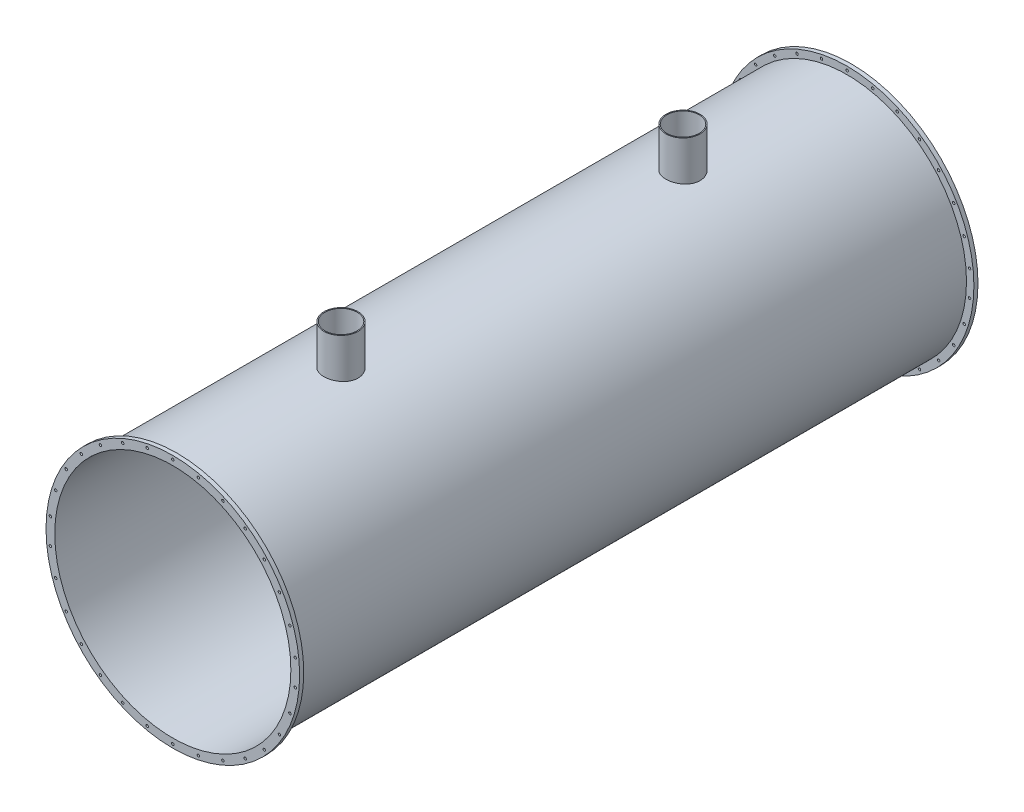
from build123d import *

# Parameters (mm, degrees)
SKETCH1_R           = 2130.025
SKETCH1_R_2         = 2105.58
BOSS_EXTRUDE1_DEPTH = 12100
BOSS_EXTRUDE2_REACH = 4962.049
SKETCH2_R           = 304.8
SKETCH3_R           = 287.4
CUT_EXTRUDE1_DEPTH  = 1000
SKETCH4_R           = 2262.0235
SKETCH4_R_2         = 2130.025
BOSS_EXTRUDE3_DEPTH = 73
SKETCH5_R           = 22
CUT_EXTRUDE2_DEPTH  = 73
SKETCH6_R           = 2262.0235
SKETCH6_R_2         = 2130.025
BOSS_EXTRUDE4_DEPTH = 73
SKETCH7_R           = 22
CUT_EXTRUDE3_DEPTH  = 73


with BuildPart() as part:
    # Sketch1 → Boss-Extrude1 (new body)
    with BuildSketch(Plane.XY):
        Circle(SKETCH1_R)
        Circle(SKETCH1_R_2, mode=Mode.SUBTRACT)
    extrude(amount=BOSS_EXTRUDE1_DEPTH)

    # Sketch2 → Boss-Extrude2 (add, up to next)
    with BuildSketch(Plane(origin=(0, 2830.0235, 0), x_dir=(1, 0, 0), z_dir=(0, 1, 0)), mode=Mode.PRIVATE) as boss_extrude2_sk1:
        with Locations((0, -3000)):
            Circle(SKETCH2_R)
    boss_extrude2_tool1 = extrude(boss_extrude2_sk1.sketch, amount=-BOSS_EXTRUDE2_REACH, mode=Mode.PRIVATE) - part.part
    add(boss_extrude2_tool1.solids().sort_by_distance((0, 2830.0235, 3000))[0])
    # Sketch2 → Boss-Extrude2 (add, up to next)
    with BuildSketch(Plane(origin=(0, 2830.0235, 0), x_dir=(1, 0, 0), z_dir=(0, 1, 0)), mode=Mode.PRIVATE) as boss_extrude2_sk2:
        with Locations((0, -9100)):
            Circle(SKETCH2_R)
    boss_extrude2_tool2 = extrude(boss_extrude2_sk2.sketch, amount=-BOSS_EXTRUDE2_REACH, mode=Mode.PRIVATE) - part.part
    add(boss_extrude2_tool2.solids().sort_by_distance((0, 2830.0235, 9100))[0])

    # Sketch3 → Cut-Extrude1 (cut)
    with BuildSketch(Plane(origin=(0, 2830.0235, 0), x_dir=(1, 0, 0), z_dir=(0, 1, 0))):
        with Locations((0, -9100)):
            Circle(SKETCH3_R)
        with Locations((0, -3000)):
            Circle(SKETCH3_R)
    extrude(amount=-CUT_EXTRUDE1_DEPTH, mode=Mode.SUBTRACT)

    # Sketch4 → Boss-Extrude3 (add)
    with BuildSketch(Plane.XY.offset(12100)):
        Circle(SKETCH4_R)
        Circle(SKETCH4_R_2, mode=Mode.SUBTRACT)
    extrude(amount=-BOSS_EXTRUDE3_DEPTH)

    # Sketch5 → Cut-Extrude2 (cut)
    with BuildSketch(Plane.XY.offset(12100)):
        with Locations((0, 2196.025)):
            Circle(SKETCH5_R)
        with Locations((456.579270828, 2148.036584901)):
            Circle(SKETCH5_R)
        with Locations((893.203836611, 2006.16866362)):
            Circle(SKETCH5_R)
        with Locations((1290.791108666, 1776.621545072)):
            Circle(SKETCH5_R)
        with Locations((1631.964615369, 1469.427539829)):
            Circle(SKETCH5_R)
        with Locations((1901.813437346, 1098.0125)):
            Circle(SKETCH5_R)
        with Locations((2088.543886197, 678.609045072)):
            Circle(SKETCH5_R)
        with Locations((2183.994945276, 229.547118548)):
            Circle(SKETCH5_R)
        with Locations((2183.994945276, -229.547118547)):
            Circle(SKETCH5_R)
        with Locations((2088.543886197, -678.609045072)):
            Circle(SKETCH5_R)
        with Locations((1901.813437346, -1098.0125)):
            Circle(SKETCH5_R)
        with Locations((1631.964615369, -1469.427539829)):
            Circle(SKETCH5_R)
        with Locations((1290.791108666, -1776.621545072)):
            Circle(SKETCH5_R)
        with Locations((893.203836611, -2006.16866362)):
            Circle(SKETCH5_R)
        with Locations((456.579270828, -2148.036584901)):
            Circle(SKETCH5_R)
        with Locations((0, -2196.025)):
            Circle(SKETCH5_R)
        with Locations((-456.579270828, -2148.036584901)):
            Circle(SKETCH5_R)
        with Locations((-893.20383661, -2006.16866362)):
            Circle(SKETCH5_R)
        with Locations((-1290.791108665, -1776.621545072)):
            Circle(SKETCH5_R)
        with Locations((-1631.964615369, -1469.427539829)):
            Circle(SKETCH5_R)
        with Locations((-1901.813437345, -1098.0125)):
            Circle(SKETCH5_R)
        with Locations((-2088.543886197, -678.609045072)):
            Circle(SKETCH5_R)
        with Locations((-2183.994945276, -229.547118548)):
            Circle(SKETCH5_R)
        with Locations((-2183.994945276, 229.547118547)):
            Circle(SKETCH5_R)
        with Locations((-2088.543886197, 678.609045072)):
            Circle(SKETCH5_R)
        with Locations((-1901.813437346, 1098.0125)):
            Circle(SKETCH5_R)
        with Locations((-1631.964615369, 1469.427539829)):
            Circle(SKETCH5_R)
        with Locations((-1290.791108666, 1776.621545072)):
            Circle(SKETCH5_R)
        with Locations((-893.203836611, 2006.16866362)):
            Circle(SKETCH5_R)
        with Locations((-456.579270828, 2148.036584901)):
            Circle(SKETCH5_R)
    extrude(amount=-CUT_EXTRUDE2_DEPTH, mode=Mode.SUBTRACT)

    # Sketch6 → Boss-Extrude4 (add)
    with BuildSketch(Plane(origin=(0, 0, 0), x_dir=(-1, 0, 0), z_dir=(0, 0, -1))):
        Circle(SKETCH6_R)
        Circle(SKETCH6_R_2, mode=Mode.SUBTRACT)
    extrude(amount=-BOSS_EXTRUDE4_DEPTH)

    # Sketch7 → Cut-Extrude3 (cut)
    with BuildSketch(Plane(origin=(0, 0, 0), x_dir=(-1, 0, 0), z_dir=(0, 0, -1))):
        with Locations((-1631.964615369, 1469.427539829)):
            Circle(SKETCH7_R)
        with Locations((-1290.791108666, 1776.621545072)):
            Circle(SKETCH7_R)
        with Locations((-893.203836611, 2006.16866362)):
            Circle(SKETCH7_R)
        with Locations((-456.579270828, 2148.036584901)):
            Circle(SKETCH7_R)
        with Locations((0, 2196.025)):
            Circle(SKETCH7_R)
        with Locations((-1290.791108666, -1776.621545072)):
            Circle(SKETCH7_R)
        with Locations((-1631.964615369, -1469.427539829)):
            Circle(SKETCH7_R)
        with Locations((-1901.813437346, -1098.0125)):
            Circle(SKETCH7_R)
        with Locations((-2088.543886197, -678.609045072)):
            Circle(SKETCH7_R)
        with Locations((-2183.994945276, -229.547118547)):
            Circle(SKETCH7_R)
        with Locations((-2183.994945276, 229.547118548)):
            Circle(SKETCH7_R)
        with Locations((-2088.543886197, 678.609045072)):
            Circle(SKETCH7_R)
        with Locations((-1901.813437346, 1098.0125)):
            Circle(SKETCH7_R)
        with Locations((1901.813437345, -1098.0125)):
            Circle(SKETCH7_R)
        with Locations((1631.964615369, -1469.427539829)):
            Circle(SKETCH7_R)
        with Locations((1290.791108665, -1776.621545072)):
            Circle(SKETCH7_R)
        with Locations((893.20383661, -2006.16866362)):
            Circle(SKETCH7_R)
        with Locations((456.579270828, -2148.036584901)):
            Circle(SKETCH7_R)
        with Locations((0, -2196.025)):
            Circle(SKETCH7_R)
        with Locations((-456.579270828, -2148.036584901)):
            Circle(SKETCH7_R)
        with Locations((-893.203836611, -2006.16866362)):
            Circle(SKETCH7_R)
        with Locations((893.203836611, 2006.16866362)):
            Circle(SKETCH7_R)
        with Locations((1290.791108666, 1776.621545072)):
            Circle(SKETCH7_R)
        with Locations((1631.964615369, 1469.427539829)):
            Circle(SKETCH7_R)
        with Locations((1901.813437346, 1098.0125)):
            Circle(SKETCH7_R)
        with Locations((2088.543886197, 678.609045072)):
            Circle(SKETCH7_R)
        with Locations((2183.994945276, 229.547118547)):
            Circle(SKETCH7_R)
        with Locations((2183.994945276, -229.547118548)):
            Circle(SKETCH7_R)
        with Locations((2088.543886197, -678.609045072)):
            Circle(SKETCH7_R)
        with Locations((456.579270828, 2148.036584901)):
            Circle(SKETCH7_R)
    extrude(amount=-CUT_EXTRUDE3_DEPTH, mode=Mode.SUBTRACT)


solid = part.part
